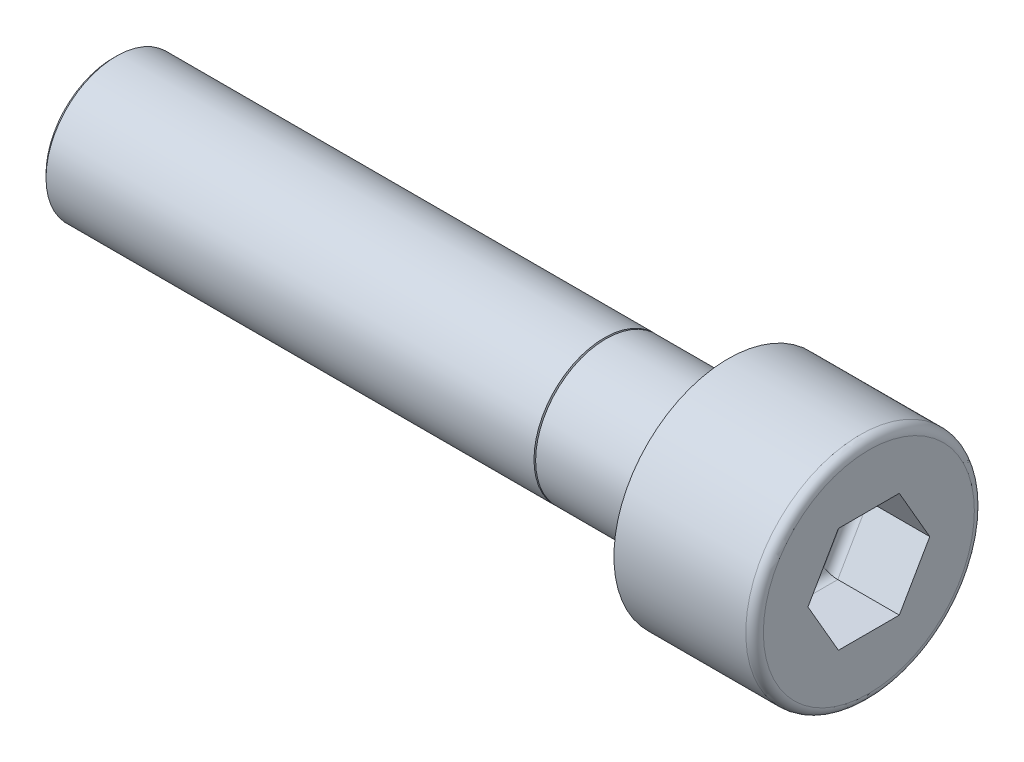
from build123d import *

# Parameters (mm, degrees)
ESQUISSE1_R             = 6.5
BOSS_EXTRU_1_DEPTH      = 8
CONG_1_R                = 0.5
ENL_V_MAT_EXTRU_1_DEPTH = 4
CONG_2_R                = 0.5
ESQUISSE3_R             = 4
BOSS_EXTRU_2_DEPTH      = 35
CHANFREIN1_SIZE         = 0.2


with BuildPart() as part:
    # Esquisse1 → Boss.-Extru.1 (new body)
    with BuildSketch(Plane(origin=(0, 0, 0), x_dir=(0, 0, -1), z_dir=(1, 0, 0))):
        Circle(ESQUISSE1_R)
    extrude(amount=BOSS_EXTRU_1_DEPTH)

    # Congé1
    cong_1_edges = [part.edges().sort_by_distance(p)[0] for p in [
        (8, 0, 6.5),
    ]]
    fillet(cong_1_edges, radius=CONG_1_R)

    # Esquisse2 → Enlèv. mat.-Extru.1 (cut)
    with BuildSketch(Plane(origin=(8, 0, 0), x_dir=(0, 0, -1), z_dir=(1, 0, 0))):
        Polygon((1.732050808, -3), (3.464101615, 0), (1.732050808, 3), (-1.732050808, 3), (-3.464101615, 0), (-1.732050808, -3), align=None)
    extrude(amount=-ENL_V_MAT_EXTRU_1_DEPTH, mode=Mode.SUBTRACT)

    # Congé2
    cong_2_edges = [part.edges().sort_by_distance(p)[0] for p in [
        (4, -3, 0),
        (4, -1.5, 2.598076211),
        (4, 1.5, 2.598076211),
        (4, 3, 0),
        (4, 1.5, -2.598076211),
        (4, -1.5, -2.598076211),
    ]]
    fillet(cong_2_edges, radius=CONG_2_R)

    # Esquisse3 → Boss.-Extru.2 (add)
    with BuildSketch(Plane.ZY):
        with Locations(Location((0, 0, 0), (0, 0, 180))):  # turned: the seam where the file's is
            Circle(ESQUISSE3_R)
    extrude(amount=BOSS_EXTRU_2_DEPTH)

    # Esquisse4 → Enlèvement de matière-Révolution1 (revolve, cut)
    with BuildSketch(Plane(origin=(0, 0, 0), x_dir=(1, 0, 0), z_dir=(0, 1, 0))):
        Polygon((-7.046630766, 4), (-7, 3.9), (-6.953369234, 4), align=None)
    revolve(axis=Axis((-35, 0, 0), (1, 0, 0)), mode=Mode.SUBTRACT)

    # Chanfrein1
    chanfrein1_edges = [part.edges().sort_by_distance(p)[0] for p in [
        (-35, 0, 4),
    ]]
    chamfer(chanfrein1_edges, length=CHANFREIN1_SIZE)


solid = part.part
